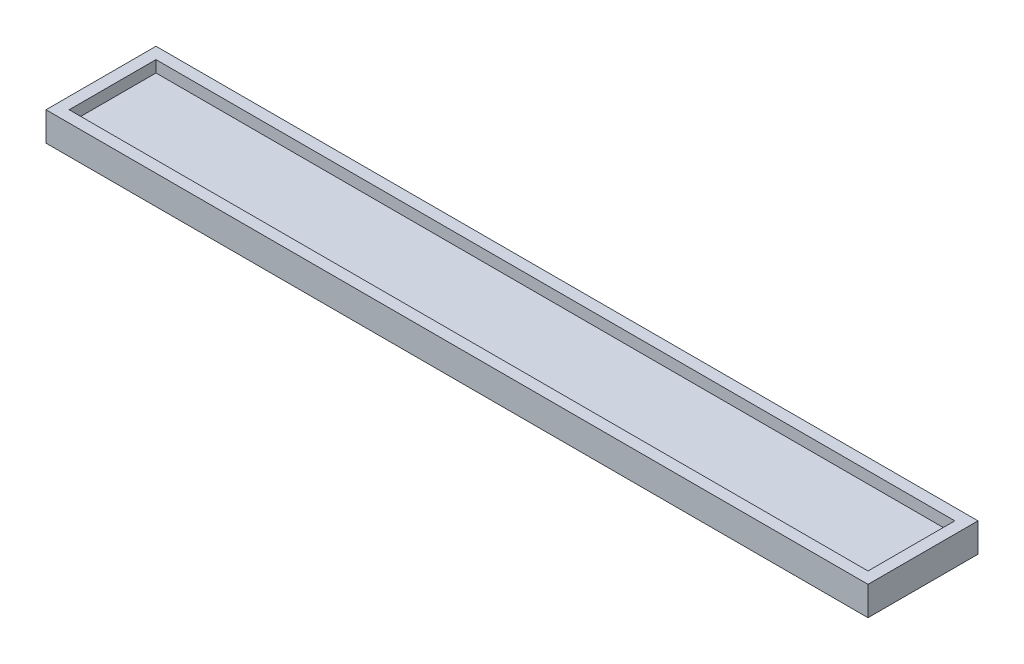
from build123d import *

# Parameters (mm, degrees)
SKETCH1_W           = 138
SKETCH1_H           = 15
BOSS_EXTRUDE1_DEPTH = 3
SKETCH2_W           = 142
SKETCH2_H           = 19
SKETCH2_W_2         = 138
SKETCH2_H_2         = 15
BOSS_EXTRUDE2_DEPTH = 5


with BuildPart() as part:
    # Sketch1 → Boss-Extrude1 (new body)
    with BuildSketch(Plane(origin=(0, 0, 0), x_dir=(1, 0, 0), z_dir=(0, 1, 0))):
        with Locations((69, 7.5)):
            Rectangle(SKETCH1_W, SKETCH1_H)
    extrude(amount=BOSS_EXTRUDE1_DEPTH)

    # Sketch2 → Boss-Extrude2 (add)
    with BuildSketch(Plane.XZ):
        with Locations((69, -7.5)):
            Rectangle(SKETCH2_W, SKETCH2_H)
        with Locations((69, -7.5)):
            Rectangle(SKETCH2_W_2, SKETCH2_H_2, mode=Mode.SUBTRACT)
    extrude(amount=-BOSS_EXTRUDE2_DEPTH)


solid = part.part
